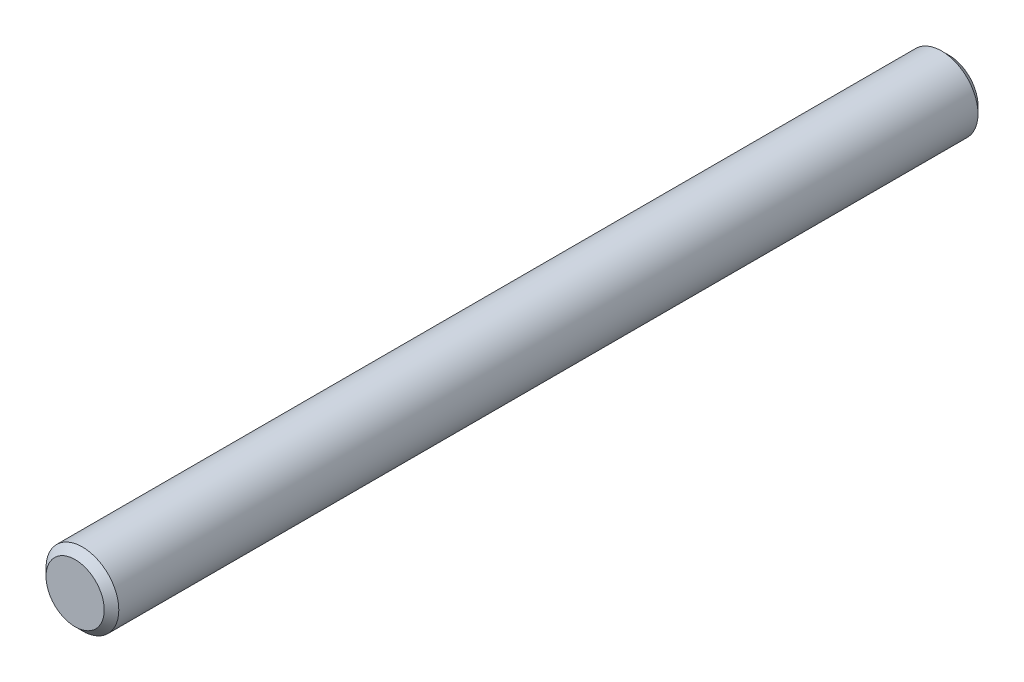
from build123d import *

# Parameters (mm, degrees)
SKETCH3_R           = 3.175
BOSS_EXTRUDE1_DEPTH = 38.1
CHAMFER1_SIZE       = 0.635


with BuildPart() as part:
    # Sketch3 → Boss-Extrude1 (new body, symmetric)
    with BuildSketch(Plane.XY):
        Circle(SKETCH3_R)
    extrude(amount=BOSS_EXTRUDE1_DEPTH, both=True)

    # Chamfer1
    chamfer1_edges = [part.edges().sort_by_distance(p)[0] for p in [
        (-3.175, 0, -38.1),
        (-3.175, 0, 38.1),
    ]]
    chamfer(chamfer1_edges, length=CHAMFER1_SIZE)


solid = part.part
